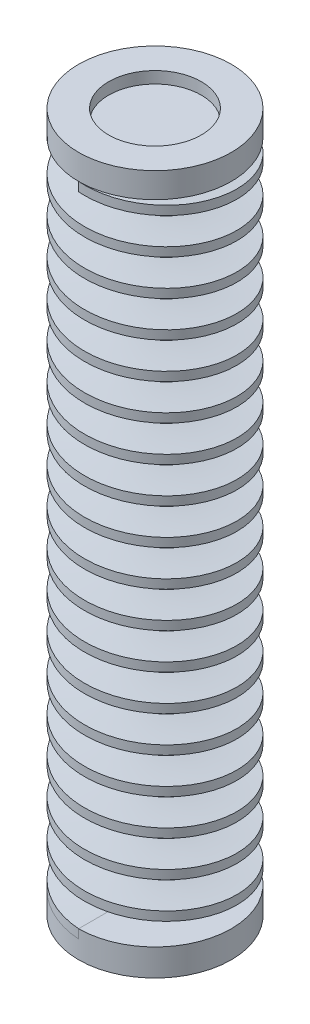
from build123d import *

# Parameters (mm, degrees)
SWEEP1_PITCH         = 4
SWEEP1_HEIGHT        = 72
SWEEP1_RADIUS        = 7.5
SKETCH4_W            = 4.25
SKETCH4_H            = 1
SKETCH5_R            = 8.5
BOSS_EXTRUDE1_DEPTH  = 2
SKETCH6_R            = 8.5
SKETCH6_R_2          = 5.15
BOSS_EXTRUDE2_DEPTH  = 1
SKETCH13_R           = 8.5
BOSS_EXTRUDE9_DEPTH  = 1.5
SKETCH14_R           = 8.5
SKETCH14_R_2         = 5.15
BOSS_EXTRUDE10_DEPTH = 1.3


with BuildPart() as part:
    # Sweep1: sweep along a helix
    with BuildLine() as sweep1_path:
        Helix(SWEEP1_PITCH, SWEEP1_HEIGHT, SWEEP1_RADIUS, center=(0, 0, 0), direction=(0, 1, 0), lefthand=True)
    # Sketch4 → Sweep1 (sweep)
    with BuildSketch(Plane.XY):
        with Locations((-6.375, 0.500000002)):
            Rectangle(SKETCH4_W, SKETCH4_H)
    sweep(path=sweep1_path.line, is_frenet=True)

    # Sketch5 → Boss-Extrude1 (add)
    with BuildSketch(Plane(origin=(0, 0, 0), x_dir=(1, 0, 0), z_dir=(0, 1, 0))):
        Circle(SKETCH5_R)
    extrude(amount=-BOSS_EXTRUDE1_DEPTH)

    # Sketch6 → Boss-Extrude2 (add)
    with BuildSketch(Plane.XZ.offset(2)):
        Circle(SKETCH6_R)
        Circle(SKETCH6_R_2, mode=Mode.SUBTRACT)
    extrude(amount=BOSS_EXTRUDE2_DEPTH)


with BuildPart() as body_2:
    # Sketch13 → Boss-Extrude9 (new body)
    with BuildSketch(Plane(origin=(0, 72.000000002, 0), x_dir=(1, 0, 0), z_dir=(0, 1, 0))):
        Circle(SKETCH13_R)
    extrude(amount=BOSS_EXTRUDE9_DEPTH)

    # Sketch14 → Boss-Extrude10 (add)
    with BuildSketch(Plane(origin=(0, 73.500000002, 0), x_dir=(1, 0, 0), z_dir=(0, 1, 0))):
        Circle(SKETCH14_R)
        Circle(SKETCH14_R_2, mode=Mode.SUBTRACT)
    extrude(amount=BOSS_EXTRUDE10_DEPTH)


solid = Compound([part.part, body_2.part])
